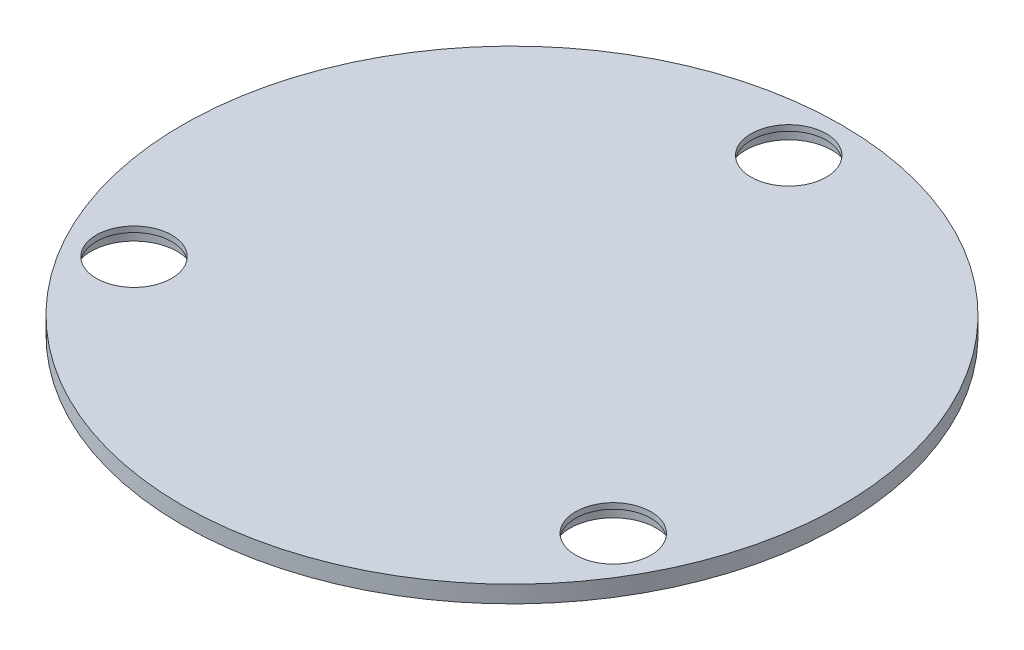
from build123d import *

# Parameters (mm, degrees)
SKETCH1_R           = 58
SKETCH1_R_2         = 6.625
BOSS_EXTRUDE1_DEPTH = 3
SKETCH2_R           = 7.6
CUT_EXTRUDE1_DEPTH  = 2


with BuildPart() as part:
    # Sketch1 → Boss-Extrude1 (new body)
    with BuildSketch(Plane(origin=(0, 0, 0), x_dir=(1, 0, 0), z_dir=(0, 1, 0))):
        Circle(SKETCH1_R)
        with Locations((0, 48.699495206)):
            Circle(SKETCH1_R_2, mode=Mode.SUBTRACT)
        with Locations((42.175, -24.349747603)):
            Circle(SKETCH1_R_2, mode=Mode.SUBTRACT)
        with Locations((-42.175, -24.349747603)):
            Circle(SKETCH1_R_2, mode=Mode.SUBTRACT)
    extrude(amount=BOSS_EXTRUDE1_DEPTH)

    # Sketch2 → Cut-Extrude1 (cut)
    with BuildSketch(Plane.XZ):
        with Locations((42.175, 24.349747603)):
            Circle(SKETCH2_R)
        with Locations((-42.175, 24.349747603)):
            Circle(SKETCH2_R)
        with Locations((0, -48.699495206)):
            Circle(SKETCH2_R)
    extrude(amount=-CUT_EXTRUDE1_DEPTH, mode=Mode.SUBTRACT)


solid = part.part
